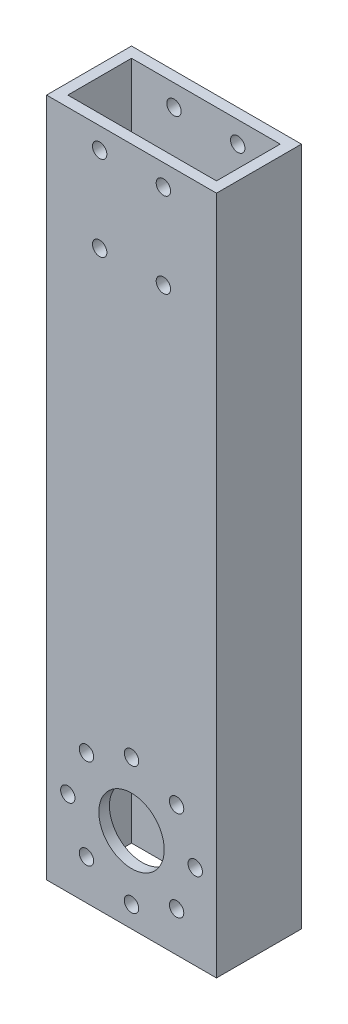
from build123d import *

# Parameters (mm, degrees)
SKETCH2_W                = 50.8
SKETCH2_H                = 25.4
SKETCH2_W_2              = 44.45
SKETCH2_H_2              = 19.05
EXTRUDE_THIN1_DEPTH      = 457.2
SKETCH25_W               = 50.8
SKETCH25_H               = 25.4
SKETCH25_W_2             = 44.45
SKETCH25_H_2             = 19.05
BOSS_EXTRUDE14_DEPTH     = 25.4
SKETCH29_W               = 50.8
SKETCH29_H               = 25.4
SKETCH29_W_2             = 44.45
SKETCH29_H_2             = 19.05
CUT_EXTRUDE10_DEPTH      = 203.2
SKETCH34_R               = 9.779
SKETCH34_R_2             = 2.15265
CUT_EXTRUDE15_DEPTH      = 25.4
SKETCH35_W               = 50.8
SKETCH35_H               = 25.4
CUT_EXTRUDE16_DEPTH      = 76.2
SKETCH31_R               = 2.15265
CUT_EXTRUDE12_DEPTH      = 1
CUT_EXTRUDE12_DEPTH_BACK = 26.4


with BuildPart() as part:
    # Sketch2 → Extrude-Thin1 (new body)
    with BuildSketch(Plane(origin=(0, 0, 0), x_dir=(1, 0, 0), z_dir=(0, 1, 0))):
        with Locations((10.213756614, 0.671957672)):
            Rectangle(SKETCH2_W, SKETCH2_H)
        with Locations((10.213756614, 0.671957672)):
            Rectangle(SKETCH2_W_2, SKETCH2_H_2, mode=Mode.SUBTRACT)
    extrude(amount=EXTRUDE_THIN1_DEPTH)

    # Sketch25 → Boss-Extrude14 (add)
    with BuildSketch(Plane.XZ):
        with Locations((10.213756614, -0.671957672)):
            Rectangle(SKETCH25_W, SKETCH25_H)
        with Locations((10.213756614, -0.671957672)):
            Rectangle(SKETCH25_W_2, SKETCH25_H_2, mode=Mode.SUBTRACT)
    extrude(amount=BOSS_EXTRUDE14_DEPTH)

    # Sketch29 → Cut-Extrude10 (cut)
    with BuildSketch(Plane(origin=(0, 457.2, 0), x_dir=(1, 0, 0), z_dir=(0, 1, 0))):
        with Locations((10.213756614, 0.671957672)):
            Rectangle(SKETCH29_W, SKETCH29_H)
        with Locations((10.213756614, 0.671957672)):
            Rectangle(SKETCH29_W_2, SKETCH29_H_2, mode=Mode.SUBTRACT)
    extrude(amount=-CUT_EXTRUDE10_DEPTH, mode=Mode.SUBTRACT)

    # Sketch34 → Cut-Extrude15 (cut)
    with BuildSketch(Plane.XY.offset(12.028042328)):
        with Locations((10.213756614, 0)):
            Circle(SKETCH34_R)
        with Locations((29.263756614, 0)):
            Circle(SKETCH34_R_2)
        with Locations((23.684140795, 13.470384182)):
            Circle(SKETCH34_R_2)
        with Locations((10.213756614, 19.05)):
            Circle(SKETCH34_R_2)
        with Locations((-3.256627568, 13.470384182)):
            Circle(SKETCH34_R_2)
        with Locations((-8.836243386, 0)):
            Circle(SKETCH34_R_2)
        with Locations((-3.256627568, -13.470384182)):
            Circle(SKETCH34_R_2)
        with Locations((10.213756614, -19.05)):
            Circle(SKETCH34_R_2)
        with Locations((23.684140795, -13.470384182)):
            Circle(SKETCH34_R_2)
    extrude(amount=-CUT_EXTRUDE15_DEPTH, mode=Mode.SUBTRACT)

    # Sketch35 → Cut-Extrude16 (cut)
    with BuildSketch(Plane(origin=(0, 254, 0), x_dir=(1, 0, 0), z_dir=(0, 1, 0))):
        with Locations((10.213756614, 0.671957672)):
            Rectangle(SKETCH35_W, SKETCH35_H)
    extrude(amount=-CUT_EXTRUDE16_DEPTH, mode=Mode.SUBTRACT)

    # Sketch31 → Cut-Extrude12 (cut, two sides)
    with BuildSketch(Plane(origin=(0, 0, -13.371957672), x_dir=(-1, 0, 0), z_dir=(0, 0, -1))) as cut_extrude12_sk:
        with Locations((-19.738756614, 146.05)):
            Circle(SKETCH31_R)
        with Locations((-0.688756614, 146.05)):
            Circle(SKETCH31_R)
        with Locations((-19.738756614, 171.45)):
            Circle(SKETCH31_R)
        with Locations((-0.688756614, 171.45)):
            Circle(SKETCH31_R)
    extrude(amount=CUT_EXTRUDE12_DEPTH, mode=Mode.SUBTRACT)
    extrude(cut_extrude12_sk.sketch, amount=-CUT_EXTRUDE12_DEPTH_BACK, mode=Mode.SUBTRACT)


solid = part.part
